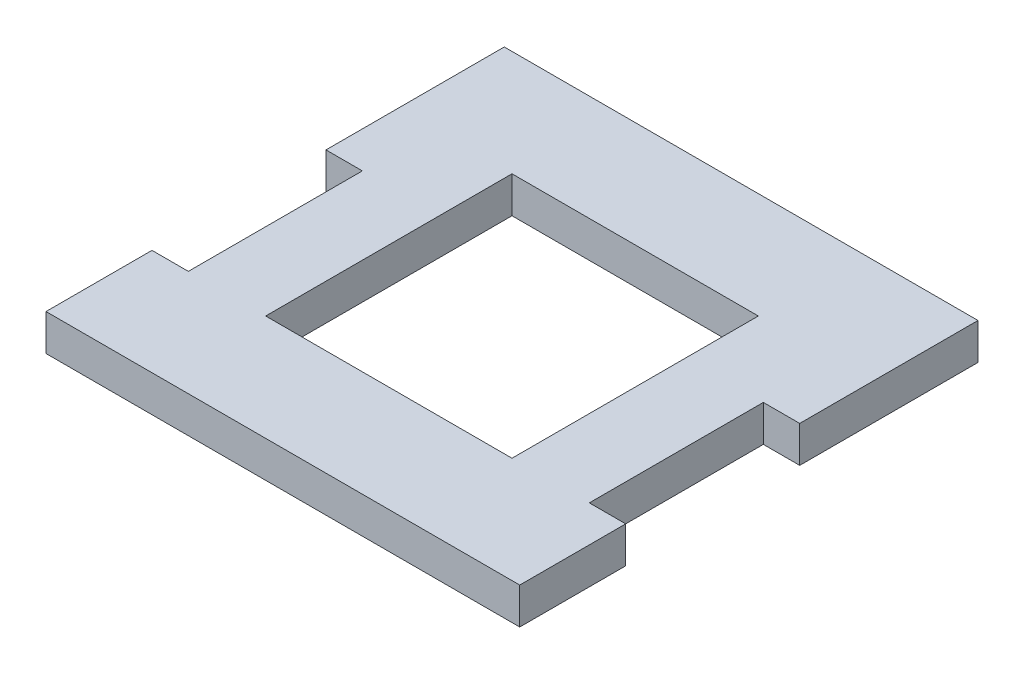
from build123d import *

# Parameters (mm, degrees)
SKETCH1_W           = 41.35
SKETCH1_H           = 40
SKETCH1_W_2         = 21.5
SKETCH1_H_2         = 21.5
BOSS_EXTRUDE1_DEPTH = 3.175
SKETCH2_W           = 3.175
SKETCH2_H           = 15.188
CUT_EXTRUDE1_DEPTH  = 4.175


with BuildPart() as part:
    # Sketch1 → Boss-Extrude1 (new body)
    with BuildSketch(Plane(origin=(0, 0, 0), x_dir=(1, 0, 0), z_dir=(0, 1, 0))):
        with Locations((20.675, 20)):
            Rectangle(SKETCH1_W, SKETCH1_H)
        with Locations((20.675, 20)):
            Rectangle(SKETCH1_W_2, SKETCH1_H_2, mode=Mode.SUBTRACT)
    extrude(amount=BOSS_EXTRUDE1_DEPTH)

    # Sketch2 → Cut-Extrude1 (cut, through all)
    with BuildSketch(Plane(origin=(0, 3.175, 0), x_dir=(1, 0, 0), z_dir=(0, 1, 0))):
        with Locations((39.7625, 16.844)):
            Rectangle(SKETCH2_W, SKETCH2_H)
        with Locations((1.5875, 16.844)):
            Rectangle(SKETCH2_W, SKETCH2_H)
    extrude(amount=-CUT_EXTRUDE1_DEPTH, mode=Mode.SUBTRACT)


solid = part.part
